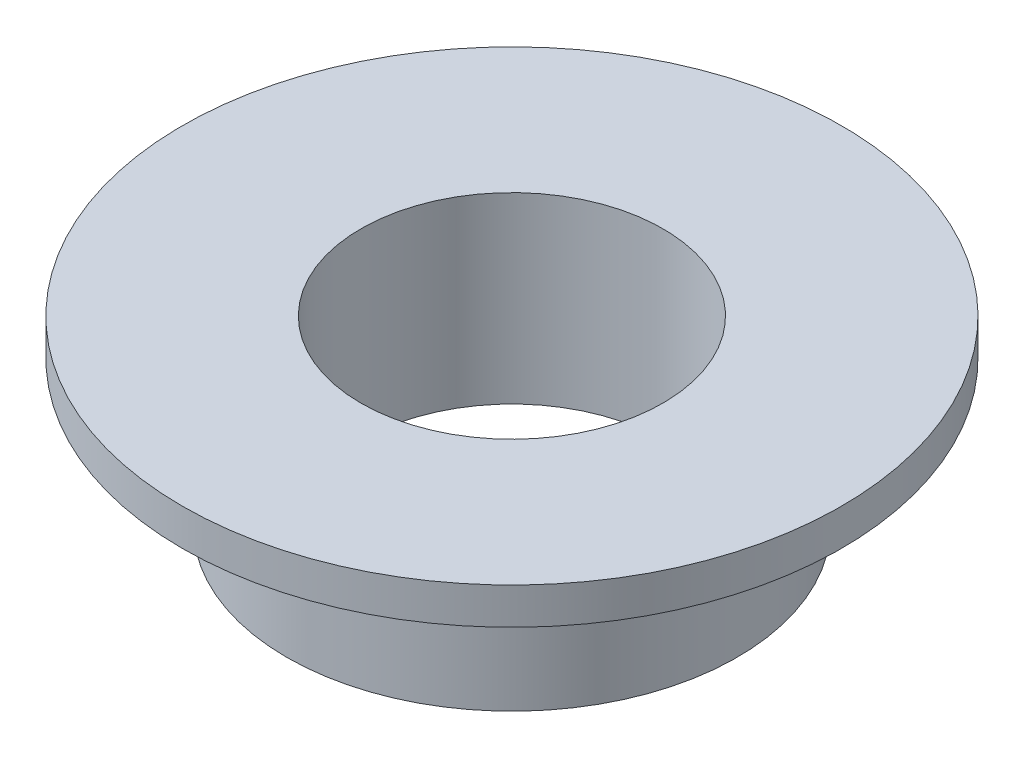
from build123d import *

# Parameters (mm, degrees)
SKETCH1_R           = 6.15
SKETCH1_R_2         = 4.125
BOSS_EXTRUDE1_DEPTH = 4
SKETCH2_R           = 9
SKETCH2_R_2         = 4.125
BOSS_EXTRUDE2_DEPTH = 1


with BuildPart() as part:
    # Sketch1 → Boss-Extrude1 (new body)
    with BuildSketch(Plane(origin=(0, 0, 0), x_dir=(1, 0, 0), z_dir=(0, 1, 0))):
        Circle(SKETCH1_R)
        Circle(SKETCH1_R_2, mode=Mode.SUBTRACT)
    extrude(amount=BOSS_EXTRUDE1_DEPTH)

    # Sketch2 → Boss-Extrude2 (add)
    with BuildSketch(Plane(origin=(0, 4, 0), x_dir=(1, 0, 0), z_dir=(0, 1, 0))):
        Circle(SKETCH2_R)
        Circle(SKETCH2_R_2, mode=Mode.SUBTRACT)
    extrude(amount=BOSS_EXTRUDE2_DEPTH)


solid = part.part
